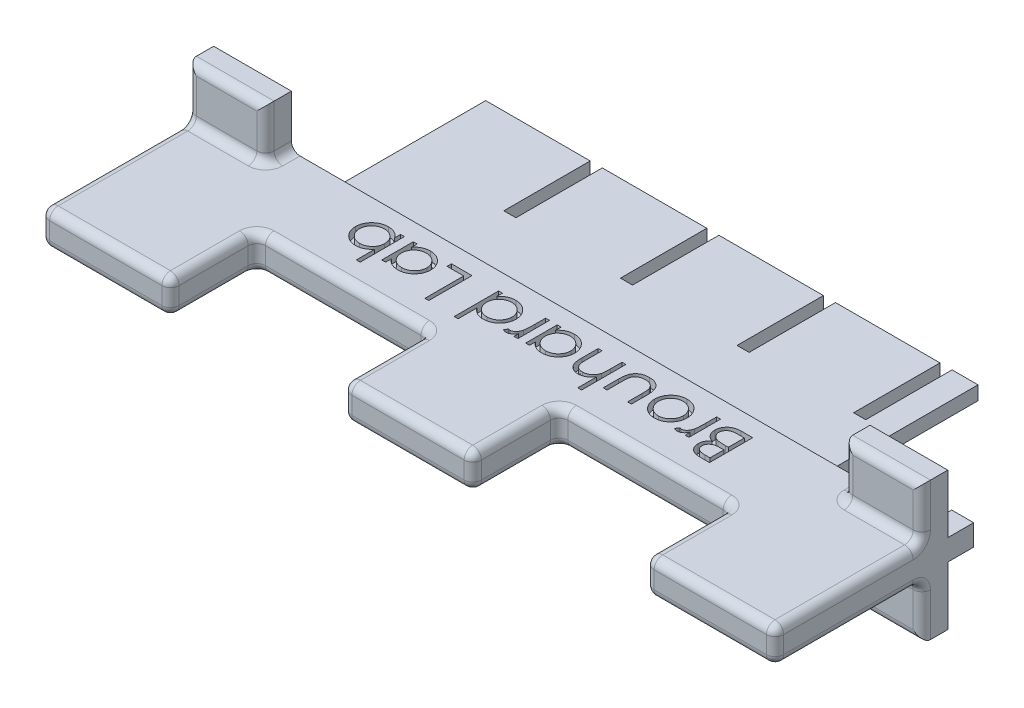
from build123d import *

# Parameters (mm, degrees)
SKETCH1_W           = 85
SKETCH1_H           = 4
BOSS_EXTRUDE1_DEPTH = 10
SKETCH2_W           = 15
SKETCH2_H           = 4
BOSS_EXTRUDE2_DEPTH = 10
SKETCH3_W           = 2.55
SKETCH3_H           = 2.45
BOSS_EXTRUDE3_DEPTH = 3
SKETCH4_W           = 57
SKETCH4_H           = 1.6
BOSS_EXTRUDE4_DEPTH = 7.5
SKETCH6_W           = 9
SKETCH6_H           = 6
BOSS_EXTRUDE6_DEPTH = 3
FILLET1_R           = 1
CUT_EXTRUDE1_DEPTH  = 1
SKETCH5_W           = 12.1
SKETCH5_H           = 1.6
SKETCH5_W_2         = 3
BOSS_EXTRUDE5_DEPTH = 10


with BuildPart() as part:
    # Sketch1 → Boss-Extrude1 (new body)
    with BuildSketch(Plane.XY):
        Rectangle(SKETCH1_W, SKETCH1_H)
    extrude(amount=BOSS_EXTRUDE1_DEPTH)

    # Sketch2 → Boss-Extrude2 (add)
    with BuildSketch(Plane.XY.offset(10)):
        with Locations((-35, 0)):
            Rectangle(SKETCH2_W, SKETCH2_H)
        with Locations((35, 0)):
            Rectangle(SKETCH2_W, SKETCH2_H)
        Rectangle(SKETCH2_W, SKETCH2_H)
    extrude(amount=BOSS_EXTRUDE2_DEPTH)

    # Sketch3 → Boss-Extrude3 (add)
    with BuildSketch(Plane(origin=(0, 0, 0), x_dir=(-1, 0, 0), z_dir=(0, 0, -1))):
        with Locations((-41.225, 0)):
            Rectangle(SKETCH3_W, SKETCH3_H)
        with Locations((41.225, 0)):
            Rectangle(SKETCH3_W, SKETCH3_H)
    extrude(amount=BOSS_EXTRUDE3_DEPTH)

    # Sketch4 → Boss-Extrude4 (add)
    with BuildSketch(Plane(origin=(0, 0, 0), x_dir=(-1, 0, 0), z_dir=(0, 0, -1))):
        Rectangle(SKETCH4_W, SKETCH4_H)
    extrude(amount=BOSS_EXTRUDE4_DEPTH)

    # Sketch6 → Boss-Extrude6 (add)
    with BuildSketch(Plane(origin=(0, 0, 0), x_dir=(-1, 0, 0), z_dir=(0, 0, -1))):
        with Locations((38, -5)):
            Rectangle(SKETCH6_W, SKETCH6_H)
        with Locations((38, 5)):
            Rectangle(SKETCH6_W, SKETCH6_H)
        with Locations((-38, -5)):
            Rectangle(SKETCH6_W, SKETCH6_H)
        with Locations((-38, 5)):
            Rectangle(SKETCH6_W, SKETCH6_H)
    extrude(amount=-BOSS_EXTRUDE6_DEPTH)

    # Fillet1
    fillet1_edges = [part.edges().sort_by_distance(p)[0] for p in [
        (-42.5, 5, 3),
        (-38, 2, 3),
        (-33.5, 5, 3),
        (-33.5, 2, 1.5),
        (-38, 8, 3),
        (42.5, -5, 3),
        (38, -2, 3),
        (33.5, -5, 3),
        (33.5, -2, 1.5),
        (38, -8, 3),
        (42.5, 5, 3),
        (38, 8, 3),
        (33.5, 5, 3),
        (38, 2, 3),
        (33.5, 2, 1.5),
        (-17.5, -2, 10),
        (-27.5, 0, 10),
        (-27.5, -2, 15),
        (-27.5, 2, 15),
        (-42.5, 0, 20),
        (-35, -2, 20),
        (-27.5, 0, 20),
        (-35, 2, 20),
        (17.5, 2, 10),
        (27.5, 0, 10),
        (27.5, 2, 15),
        (27.5, -2, 15),
        (42.5, 0, 20),
        (35, 2, 20),
        (27.5, 0, 20),
        (35, -2, 20),
        (17.5, -2, 10),
        (-17.5, 2, 10),
        (7.5, 0, 10),
        (7.5, -2, 15),
        (7.5, 2, 15),
        (-7.5, 0, 10),
        (-7.5, 2, 15),
        (-7.5, -2, 15),
        (7.5, 0, 20),
        (0, 2, 20),
        (-7.5, 0, 20),
        (0, -2, 20),
        (42.5, -2, 11.5),
        (-42.5, -2, 11.5),
        (-42.5, 2, 11.5),
        (42.5, 2, 11.5),
        (-42.5, -5, 3),
        (-38, -8, 3),
        (-33.5, -5, 3),
        (-38, -2, 3),
        (-33.5, -2, 1.5),
    ]]
    fillet(fillet1_edges, radius=FILLET1_R)

    # Sketch8 → Cut-Extrude1 (cut)
    with BuildSketch(Plane(origin=(0, 2, 0), x_dir=(1, 0, 0), z_dir=(0, 1, 0))):
        with BuildLine():
            Line((21.955128205, -7.045024133), (20.979567308, -7.045024133))
            add(Edge.make_bspline(
                [(20.979567308, -7.045024133), (20.931811586, -7.044777014), (20.839249111, -7.044298035), (20.704660144, -7.036696988), (20.578554958, -7.026592114), (20.461156398, -7.009641733), (20.351700568, -6.992066423), (20.251298675, -6.966270076), (20.159109728, -6.937777071), (20.048409672, -6.893936716), (19.92280529, -6.825852091), (19.787804083, -6.724876123), (19.670452795, -6.603814091), (19.570669416, -6.465854357), (19.490591132, -6.314083016), (19.43339094, -6.151765477), (19.396643358, -5.981632539), (19.392911608, -5.864990679), (19.391025641, -5.806041761)],
                knots=[0, 0, 0, 0, 0.000143243, 0.000277641, 0.000404323, 0.000522601, 0.000633422, 0.000736665, 0.000833282, 0.000922745, 0.001093491, 0.001260157, 0.001426607, 0.001597303, 0.001769346, 0.001939468, 0.002112331, 0.002288957, 0.002288957, 0.002288957, 0.002288957], degree=3))
            add(Edge.make_bspline(
                [(19.391025641, -5.806041761), (19.392566125, -5.750816773), (19.395593321, -5.642294463), (19.425166581, -5.484100137), (19.4698067, -5.333038737), (19.534225102, -5.190566035), (19.616363978, -5.057933935), (19.716298264, -4.937404803), (19.834792937, -4.831345021), (19.923759393, -4.772321243), (19.968950321, -4.742339838)],
                knots=[0, 0, 0, 0, 0.00016551, 0.000325243, 0.000481139, 0.000637145, 0.000792791, 0.000947835, 0.001105294, 0.001267844, 0.001267844, 0.001267844, 0.001267844], degree=3))
            add(Edge.make_bspline(
                [(19.968950321, -4.742339838), (19.912145679, -4.720542475), (19.803464327, -4.678838718), (19.653711211, -4.604821394), (19.524645211, -4.524933301), (19.41460302, -4.438588883), (19.32239544, -4.34296875), (19.240253224, -4.240591123), (19.170541651, -4.127890536), (19.111062126, -4.007309158), (19.063944891, -3.879485542), (19.031238978, -3.745375962), (19.010496783, -3.606499394), (19.007784363, -3.512111636), (19.006410256, -3.464294967)],
                knots=[0, 0, 0, 0, 0.000182459, 0.00034909, 0.000500276, 0.000637148, 0.000767471, 0.00089793, 0.001030217, 0.001164151, 0.001300726, 0.001437979, 0.001577644, 0.001721044, 0.001721044, 0.001721044, 0.001721044], degree=3))
            add(Edge.make_bspline(
                [(19.006410256, -3.464294967), (19.007805885, -3.41548523), (19.010551822, -3.319450707), (19.030807012, -3.178370784), (19.065112767, -3.043553694), (19.112331393, -2.914102037), (19.173883248, -2.790773975), (19.248244287, -2.672600284), (19.337493216, -2.561332318), (19.437996289, -2.45535544), (19.550128803, -2.358444164), (19.673690061, -2.2751618), (19.805513315, -2.203227398), (19.947403728, -2.145396174), (20.098354491, -2.100124903), (20.258400966, -2.068824422), (20.427452272, -2.047649449), (20.543467886, -2.045914087), (20.602964744, -2.045024133)],
                knots=[0, 0, 0, 0, 0.000146402, 0.00028805, 0.000426518, 0.000563092, 0.000700608, 0.000839267, 0.000981145, 0.001127794, 0.001276955, 0.001424748, 0.00157399, 0.001726698, 0.001883553, 0.002046002, 0.002215459, 0.002393845, 0.002393845, 0.002393845, 0.002393845], degree=3))
            Line((20.602964744, -2.045024133), (21.955128205, -2.045024133))
            Line((21.955128205, -2.045024133), (21.955128205, -7.045024133))
        make_face()
        with BuildLine():
            Line((21.506410256, -6.53220362), (21.506410256, -4.929639518))
            Line((21.506410256, -4.929639518), (21.204927885, -4.929639518))
            add(Edge.make_bspline(
                [(21.204927885, -4.929639518), (21.16085778, -4.930206082), (21.075705357, -4.9313008), (20.952063514, -4.934535484), (20.837581625, -4.943196106), (20.731865233, -4.952356158), (20.635622811, -4.966460704), (20.548532434, -4.983720889), (20.469810894, -5.00181496), (20.379071632, -5.032675643), (20.276157749, -5.077807077), (20.16721677, -5.149562501), (20.069164992, -5.232639769), (19.988277934, -5.331182392), (19.920936523, -5.437599512), (19.875598165, -5.552684686), (19.843986577, -5.672472047), (19.841172407, -5.755083607), (19.83974359, -5.797027338)],
                knots=[0, 0, 0, 0, 0.000132227, 0.000255489, 0.000370952, 0.000476596, 0.000573767, 0.000662554, 0.000742964, 0.000815812, 0.000949851, 0.001078759, 0.001205868, 0.001333854, 0.001459773, 0.001581973, 0.001703679, 0.001829203, 0.001829203, 0.001829203, 0.001829203], degree=3))
            add(Edge.make_bspline(
                [(19.83974359, -5.797027338), (19.840440447, -5.824795004), (19.841807408, -5.879264312), (19.85469429, -5.958622966), (19.872478035, -6.034141042), (19.901807859, -6.103782707), (19.936556119, -6.169993364), (19.98109509, -6.230681546), (20.03245262, -6.287491301), (20.092329064, -6.338899898), (20.160479658, -6.385396007), (20.239063252, -6.424101797), (20.325943351, -6.458499162), (20.422931675, -6.48457317), (20.528096305, -6.507209559), (20.643041681, -6.521483941), (20.767075062, -6.530654029), (20.853013063, -6.531675569), (20.897435897, -6.53220362)],
                knots=[0, 0, 0, 0, 8.3229e-05, 0.000163264, 0.000240757, 0.000315341, 0.000389283, 0.000464617, 0.000540481, 0.000618594, 0.000700823, 0.000787274, 0.000880832, 0.000980716, 0.001088168, 0.001203335, 0.00132786, 0.001461107, 0.001461107, 0.001461107, 0.001461107], degree=3))
            Line((20.897435897, -6.53220362), (21.506410256, -6.53220362))
        make_face(mode=Mode.SUBTRACT)
        with BuildLine():
            Line((21.506410256, -4.416819005), (21.506410256, -2.557844646))
            Line((21.506410256, -2.557844646), (20.867387821, -2.557844646))
            add(Edge.make_bspline(
                [(20.867387821, -2.557844646), (20.82165107, -2.558445571), (20.733499514, -2.559603775), (20.606126985, -2.562352033), (20.48869926, -2.57254806), (20.380238634, -2.582323383), (20.281246941, -2.598293401), (20.190761319, -2.61375789), (20.110848501, -2.63651465), (20.017345889, -2.667828353), (19.912764158, -2.717871803), (19.798555972, -2.791464981), (19.697962318, -2.881106895), (19.612615651, -2.984324471), (19.541653639, -3.095395221), (19.492561941, -3.214537751), (19.460753316, -3.337772506), (19.457007017, -3.422035912), (19.455128205, -3.464294967)],
                knots=[0, 0, 0, 0, 0.000137234, 0.000264501, 0.000382034, 0.000490767, 0.000591058, 0.000682796, 0.000765899, 0.000840017, 0.000978463, 0.001112367, 0.001246451, 0.001380849, 0.001513136, 0.001640186, 0.001766022, 0.001892621, 0.001892621, 0.001892621, 0.001892621], degree=3))
            add(Edge.make_bspline(
                [(19.455128205, -3.464294967), (19.455511728, -3.490717987), (19.456272588, -3.543137822), (19.468232548, -3.620102651), (19.484829912, -3.695025725), (19.509289766, -3.766889341), (19.538879538, -3.836930979), (19.577915987, -3.902871611), (19.621948812, -3.967518228), (19.690148998, -4.050208407), (19.790699472, -4.144331407), (19.933635519, -4.235332182), (20.095250073, -4.309910154), (20.212743455, -4.341437989), (20.2734375, -4.357724454)],
                knots=[0, 0, 0, 0, 7.9184e-05, 0.00015709, 0.000233139, 0.000309156, 0.000384516, 0.000460796, 0.000538586, 0.000618995, 0.000781989, 0.000949233, 0.001125381, 0.001313608, 0.001313608, 0.001313608, 0.001313608], degree=3))
            add(Edge.make_bspline(
                [(20.2734375, -4.357724454), (20.297764757, -4.36266062), (20.350511268, -4.373363246), (20.436522534, -4.384653585), (20.535045896, -4.394781387), (20.645660247, -4.402076233), (20.768805516, -4.409907124), (20.904442139, -4.412844185), (21.052666008, -4.416429024), (21.15551238, -4.416685686), (21.208934295, -4.416819005)],
                knots=[0, 0, 0, 0, 7.4449e-05, 0.000161422, 0.000260089, 0.000371555, 0.000493951, 0.000630228, 0.000778496, 0.000938755, 0.000938755, 0.000938755, 0.000938755], degree=3))
            Line((21.208934295, -4.416819005), (21.506410256, -4.416819005))
        make_face(mode=Mode.SUBTRACT)
        with BuildLine():
            Line((18.237179487, -5.698870287), (17.788461538, -5.698870287))
            Line((17.788461538, -5.698870287), (17.788461538, -5.16100971))
            add(Edge.make_bspline(
                [(17.788461538, -5.16100971), (17.755359908, -5.211117117), (17.692053298, -5.306947144), (17.586273377, -5.43343718), (17.479111393, -5.53983342), (17.366921794, -5.622588498), (17.252557594, -5.685650706), (17.136357118, -5.730343447), (17.017481778, -5.757585182), (16.937237879, -5.761174556), (16.897035256, -5.762972851)],
                knots=[0, 0, 0, 0, 0.000180032, 0.00034431, 0.000493764, 0.000631989, 0.000761087, 0.000884414, 0.00100446, 0.00112499, 0.00112499, 0.00112499, 0.00112499], degree=3))
            add(Edge.make_bspline(
                [(16.897035256, -5.762972851), (16.865844687, -5.761310147), (16.801992924, -5.757906343), (16.705041331, -5.732794344), (16.604739598, -5.694222955), (16.540012887, -5.657063647), (16.506410256, -5.637772531)],
                knots=[0, 0, 0, 0, 9.3493e-05, 0.000191394, 0.000298902, 0.000414971, 0.000414971, 0.000414971, 0.000414971], degree=3))
            Line((16.506410256, -5.637772531), (16.752804487, -5.249150736))
            add(Edge.make_bspline(
                [(16.752804487, -5.249150736), (16.774388803, -5.258779687), (16.815359967, -5.277057281), (16.875295061, -5.298688724), (16.930554114, -5.311425747), (16.965759197, -5.313355343), (16.982171474, -5.314254902)],
                knots=[0, 0, 0, 0, 7.0888e-05, 0.000134558, 0.000190943, 0.000240184, 0.000240184, 0.000240184, 0.000240184], degree=3))
            add(Edge.make_bspline(
                [(16.982171474, -5.314254902), (17.018552318, -5.311962095), (17.092095887, -5.307327204), (17.199553418, -5.267726819), (17.305221395, -5.20820996), (17.387285817, -5.138004944), (17.451536641, -5.071852679), (17.497773588, -5.013639038), (17.539299542, -4.947803919), (17.579572406, -4.876841023), (17.616991286, -4.798984205), (17.65042989, -4.714102186), (17.681701622, -4.622897124), (17.699312387, -4.559480067), (17.708333333, -4.526995287)],
                knots=[0, 0, 0, 0, 0.000108839, 0.000220017, 0.000339778, 0.000471355, 0.000542193, 0.000616339, 0.000693851, 0.000775474, 0.000861039, 0.000952734, 0.001049023, 0.001150145, 0.001150145, 0.001150145, 0.001150145], degree=3))
            add(Edge.make_bspline(
                [(17.708333333, -4.526995287), (17.715105579, -4.4980295), (17.73018081, -4.433550753), (17.744447085, -4.325868753), (17.75911049, -4.198727857), (17.769124119, -4.051980366), (17.778583328, -3.885062178), (17.783808984, -3.698693379), (17.788295276, -3.492361731), (17.78840435, -3.348446216), (17.788461538, -3.272988877)],
                knots=[0, 0, 0, 0, 8.9193e-05, 0.000198547, 0.000325526, 0.000473173, 0.000639683, 0.000827079, 0.001032447, 0.001258811, 0.001258811, 0.001258811, 0.001258811], degree=3))
            Line((17.788461538, -3.272988877), (17.788461538, -2.045024133))
            Line((17.788461538, -2.045024133), (18.237179487, -2.045024133))
            Line((18.237179487, -2.045024133), (18.237179487, -5.698870287))
        make_face()
        with BuildLine():
            add(Edge.make_bspline(
                [(14.29286859, -5.762972851), (14.224307927, -5.761517291), (14.089877222, -5.758663293), (13.893032913, -5.728009819), (13.705327588, -5.681525783), (13.525956048, -5.616093456), (13.356402056, -5.530243686), (13.195151776, -5.426425769), (13.042528278, -5.303937317), (12.951070622, -5.209132095), (12.904647436, -5.16100971)],
                knots=[0, 0, 0, 0, 0.000205526, 0.000402987, 0.000596112, 0.000784972, 0.000974447, 0.001165038, 0.001359476, 0.001559909, 0.001559909, 0.001559909, 0.001559909], degree=3))
            add(Edge.make_bspline(
                [(12.904647436, -5.16100971), (12.864673216, -5.11498973), (12.785498387, -5.023840384), (12.683975931, -4.876046652), (12.59651656, -4.722989365), (12.526426616, -4.562636041), (12.471162296, -4.396386511), (12.431925587, -4.223669352), (12.408587109, -4.044865999), (12.405440013, -3.923431945), (12.403846154, -3.861931185)],
                knots=[0, 0, 0, 0, 0.000182745, 0.000361954, 0.000536876, 0.000710881, 0.000886036, 0.001061708, 0.001241475, 0.001425944, 0.001425944, 0.001425944, 0.001425944], degree=3))
            add(Edge.make_bspline(
                [(12.403846154, -3.861931185), (12.405248064, -3.800073959), (12.408018305, -3.677841197), (12.434223472, -3.497813533), (12.474982163, -3.323249495), (12.533313369, -3.154879952), (12.608110636, -2.992190127), (12.699383171, -2.835891045), (12.807770716, -2.685672654), (12.930635425, -2.542816985), (13.066416897, -2.411135675), (13.21375075, -2.296436369), (13.369848434, -2.197755629), (13.536840837, -2.119375683), (13.712350874, -2.056195988), (13.8974949, -2.012629522), (14.09210775, -1.986052796), (14.225006973, -1.982656037), (14.29286859, -1.980921569)],
                knots=[0, 0, 0, 0, 0.00018547, 0.000366497, 0.000544574, 0.000722589, 0.000900065, 0.001080956, 0.001264689, 0.001455025, 0.001645575, 0.001831106, 0.002014249, 0.002198383, 0.002383395, 0.002572886, 0.002767942, 0.002971467, 0.002971467, 0.002971467, 0.002971467], degree=3))
            add(Edge.make_bspline(
                [(14.29286859, -1.980921569), (14.361059424, -1.982670388), (14.494614618, -1.986095539), (14.689960267, -2.012431829), (14.875883807, -2.056661478), (15.052224048, -2.118593533), (15.219215773, -2.198399418), (15.37588985, -2.296052412), (15.523293198, -2.411193757), (15.65911724, -2.542801247), (15.781970535, -2.685676709), (15.890361026, -2.835889993), (15.981632796, -2.992190401), (16.056430263, -3.154879879), (16.114761415, -3.323249515), (16.155520121, -3.497813528), (16.181725284, -3.677841198), (16.184495525, -3.80007396), (16.185897436, -3.861931185)],
                knots=[0, 0, 0, 0, 0.000204526, 0.000400574, 0.000590065, 0.000776965, 0.000960195, 0.001144188, 0.00132972, 0.001520269, 0.001710605, 0.001894339, 0.00207523, 0.002252706, 0.002430721, 0.002608798, 0.002789825, 0.002975294, 0.002975294, 0.002975294, 0.002975294], degree=3))
            add(Edge.make_bspline(
                [(16.185897436, -3.861931185), (16.184296519, -3.923099043), (16.18112698, -4.044200892), (16.157756652, -4.22264832), (16.118946868, -4.394836864), (16.062916427, -4.560178538), (15.992956591, -4.720146456), (15.90637746, -4.873764934), (15.803872945, -5.02091287), (15.725005709, -5.111941341), (15.685096154, -5.158004902)],
                knots=[0, 0, 0, 0, 0.000183468, 0.000363236, 0.000538908, 0.000712162, 0.000886167, 0.001061962, 0.001240348, 0.001423094, 0.001423094, 0.001423094, 0.001423094], degree=3))
            add(Edge.make_bspline(
                [(15.685096154, -5.158004902), (15.638739114, -5.20653651), (15.547569839, -5.301982456), (15.394241809, -5.424229232), (15.233685171, -5.529446865), (15.063037498, -5.615253429), (14.883167202, -5.681407061), (14.694066814, -5.728226774), (14.496506031, -5.758527704), (14.361424213, -5.761476369), (14.29286859, -5.762972851)],
                knots=[0, 0, 0, 0, 0.00020114, 0.000395577, 0.000586713, 0.000776188, 0.000967274, 0.001160399, 0.001359841, 0.001565367, 0.001565367, 0.001565367, 0.001565367], degree=3))
        make_face()
        with BuildLine():
            add(Edge.make_bspline(
                [(14.294871795, -5.314254902), (14.343354042, -5.31287684), (14.439066976, -5.310156289), (14.579952881, -5.289466071), (14.715578773, -5.256679949), (14.84621924, -5.210117374), (14.971369132, -5.149920796), (15.091165691, -5.076401027), (15.205288814, -4.989167289), (15.312855022, -4.88995037), (15.412753003, -4.782192755), (15.499001382, -4.666286529), (15.572889716, -4.545452386), (15.633262525, -4.419007361), (15.679580189, -4.286604065), (15.712397714, -4.149000046), (15.733127199, -4.005785755), (15.735814091, -3.908409845), (15.737179487, -3.858926377)],
                knots=[0, 0, 0, 0, 0.000145402, 0.00028705, 0.000426247, 0.000563423, 0.000702299, 0.000842129, 0.000984361, 0.00113252, 0.001280679, 0.00142451, 0.001565195, 0.001704975, 0.001844039, 0.001985183, 0.002128814, 0.002277217, 0.002277217, 0.002277217, 0.002277217], degree=3))
            add(Edge.make_bspline(
                [(15.737179487, -3.858926377), (15.734890082, -3.794992084), (15.730346041, -3.668094469), (15.693206633, -3.48126298), (15.631516344, -3.301562306), (15.546449569, -3.131156088), (15.441687276, -2.973216762), (15.31918926, -2.831196974), (15.177261944, -2.710573578), (15.020738225, -2.609127271), (14.851836243, -2.5292384), (14.673387712, -2.471947456), (14.487017459, -2.435206285), (14.359480893, -2.431511347), (14.294871795, -2.429639518)],
                knots=[0, 0, 0, 0, 0.000191683, 0.000380455, 0.000568919, 0.000760186, 0.000950198, 0.001136194, 0.00132088, 0.001507019, 0.001694298, 0.001879594, 0.002068178, 0.002261801, 0.002261801, 0.002261801, 0.002261801], degree=3))
            add(Edge.make_bspline(
                [(14.294871795, -2.429639518), (14.23025898, -2.431500504), (14.102715078, -2.435174039), (13.916085515, -2.472133599), (13.737147914, -2.528989279), (13.568070317, -2.609217501), (13.411475317, -2.710190138), (13.270561459, -2.831884154), (13.147008507, -2.972843418), (13.04214248, -3.130946672), (12.958446366, -3.301827223), (12.896465966, -3.481229869), (12.859415628, -3.668102902), (12.854859565, -3.794994909), (12.852564103, -3.858926377)],
                knots=[0, 0, 0, 0, 0.000193623, 0.000382206, 0.000568456, 0.000755734, 0.000941873, 0.001125801, 0.001312456, 0.001502468, 0.001693291, 0.001881755, 0.002070527, 0.00226221, 0.00226221, 0.00226221, 0.00226221], degree=3))
            add(Edge.make_bspline(
                [(12.852564103, -3.858926377), (12.85391927, -3.908413822), (12.856586033, -4.00579756), (12.877461924, -4.148954918), (12.909764333, -4.286878115), (12.958078967, -4.418473367), (13.016348399, -4.546067931), (13.092028067, -4.665924648), (13.177874936, -4.782266279), (13.277956043, -4.889885455), (13.385510177, -4.98952979), (13.500490643, -5.076083255), (13.620342842, -5.149962779), (13.745532283, -5.210124787), (13.875877117, -5.256500729), (14.011091241, -5.289608892), (14.151353237, -5.310080851), (14.246726302, -5.312854653), (14.294871795, -5.314254902)],
                knots=[0, 0, 0, 0, 0.000148403, 0.000292034, 0.000433178, 0.000572578, 0.00071193, 0.000853138, 0.000996969, 0.001145128, 0.001293287, 0.001436317, 0.001576147, 0.001715023, 0.001852199, 0.001990424, 0.002132072, 0.002276473, 0.002276473, 0.002276473, 0.002276473], degree=3))
        make_face(mode=Mode.SUBTRACT)
        with BuildLine():
            Line((11.570512821, -5.698870287), (11.121794872, -5.698870287))
            Line((11.121794872, -5.698870287), (11.121794872, -4.004158749))
            add(Edge.make_bspline(
                [(11.121794872, -4.004158749), (11.121592151, -3.954411964), (11.121204354, -3.859248695), (11.118574439, -3.722312714), (11.112388591, -3.597431696), (11.104654555, -3.484533501), (11.094708647, -3.383637227), (11.082875275, -3.295095289), (11.069648958, -3.217903597), (11.056702224, -3.171413089), (11.05068109, -3.149791761)],
                knots=[0, 0, 0, 0, 0.000149242, 0.000285493, 0.000410838, 0.000524302, 0.000624962, 0.000714911, 0.000792314, 0.000859608, 0.000859608, 0.000859608, 0.000859608], degree=3))
            add(Edge.make_bspline(
                [(11.05068109, -3.149791761), (11.041021805, -3.122616307), (11.02190405, -3.06883037), (10.987228565, -2.991130691), (10.944327515, -2.919170094), (10.897397624, -2.850149082), (10.843207537, -2.786203671), (10.78254961, -2.72691621), (10.716500508, -2.671595092), (10.619751651, -2.6048734), (10.487494763, -2.534263345), (10.314242396, -2.472488378), (10.126045943, -2.436112097), (9.995820794, -2.431836921), (9.928886218, -2.429639518)],
                knots=[0, 0, 0, 0, 8.6516e-05, 0.000171232, 0.000254721, 0.000337515, 0.000421387, 0.00050567, 0.000591721, 0.00067952, 0.000857864, 0.001039709, 0.001229465, 0.001430146, 0.001430146, 0.001430146, 0.001430146], degree=3))
            add(Edge.make_bspline(
                [(9.928886218, -2.429639518), (9.86194316, -2.431828713), (9.732748927, -2.436053669), (9.546518851, -2.471939165), (9.375968682, -2.530483395), (9.223089747, -2.613350563), (9.088841758, -2.714376404), (8.976981124, -2.832969142), (8.884684323, -2.965323174), (8.844385248, -3.064072442), (8.82411859, -3.113734069)],
                knots=[0, 0, 0, 0, 0.000200681, 0.000387296, 0.000566586, 0.000739571, 0.000906841, 0.001068376, 0.001227003, 0.001387484, 0.001387484, 0.001387484, 0.001387484], degree=3))
            add(Edge.make_bspline(
                [(8.82411859, -3.113734069), (8.8181224, -3.1336855), (8.80486629, -3.177793242), (8.790725551, -3.252630176), (8.777460105, -3.341789135), (8.768616165, -3.446206446), (8.758522511, -3.564961319), (8.755037146, -3.698667884), (8.750059864, -3.846538026), (8.750020544, -3.950065981), (8.75, -4.004158749)],
                knots=[0, 0, 0, 0, 6.2462e-05, 0.000138088, 0.000228176, 0.000332823, 0.000452355, 0.000585662, 0.000733953, 0.000896216, 0.000896216, 0.000896216, 0.000896216], degree=3))
            Line((8.75, -4.004158749), (8.75, -5.698870287))
            Line((8.75, -5.698870287), (8.301282051, -5.698870287))
            Line((8.301282051, -5.698870287), (8.301282051, -3.920024133))
            add(Edge.make_bspline(
                [(8.301282051, -3.920024133), (8.30191531, -3.859585653), (8.303143917, -3.742326733), (8.310980731, -3.571916291), (8.324614367, -3.412799073), (8.344773775, -3.265462167), (8.369229918, -3.129870336), (8.400154934, -3.00598092), (8.437277048, -2.893621613), (8.479165629, -2.791153018), (8.528529202, -2.698158121), (8.581390514, -2.610389295), (8.640827886, -2.528135886), (8.705652894, -2.450645369), (8.777741804, -2.379798189), (8.85333008, -2.311961845), (8.93610888, -2.251321381), (9.023288539, -2.194646502), (9.117066908, -2.144351467), (9.216637391, -2.100832577), (9.321894658, -2.063022013), (9.433003103, -2.033803946), (9.549897573, -2.009153726), (9.67242881, -1.992746928), (9.800829998, -1.982271357), (9.888132562, -1.981379054), (9.932892628, -1.980921569)],
                knots=[0, 0, 0, 0, 0.000181315, 0.000351776, 0.000511647, 0.000660239, 0.000797754, 0.000924804, 0.001042946, 0.001152506, 0.001256441, 0.001358477, 0.001459659, 0.001560587, 0.001661157, 0.001762636, 0.001865001, 0.001968632, 0.00207439, 0.002183817, 0.002294379, 0.002409546, 0.002528193, 0.002652561, 0.002780158, 0.002914407, 0.002914407, 0.002914407, 0.002914407], degree=3))
            add(Edge.make_bspline(
                [(9.932892628, -1.980921569), (9.977316456, -1.981406186), (10.064613414, -1.982358504), (10.192711845, -1.992570693), (10.315507575, -2.00940504), (10.432494069, -2.033606354), (10.544142851, -2.063257518), (10.649911875, -2.100566743), (10.749934706, -2.144600485), (10.84442655, -2.194693497), (10.933073912, -2.251115088), (11.015677547, -2.313213364), (11.093710062, -2.379368112), (11.165005381, -2.451835522), (11.23008642, -2.530073038), (11.28923533, -2.613729086), (11.343463789, -2.701858176), (11.392537938, -2.79623559), (11.434697953, -2.899909467), (11.471919623, -3.014619732), (11.502363426, -3.141623289), (11.527138371, -3.28081177), (11.547069003, -3.431518969), (11.560906348, -3.594616706), (11.568643249, -3.769707694), (11.569876194, -3.890636109), (11.570512821, -3.953077018)],
                knots=[0, 0, 0, 0, 0.000133247, 0.000261843, 0.000385219, 0.000504847, 0.000620013, 0.00073152, 0.000840947, 0.000947589, 0.001052063, 0.001155829, 0.001257407, 0.001358687, 0.001460383, 0.00156238, 0.001665793, 0.001770617, 0.001881102, 0.002001148, 0.002132087, 0.002272558, 0.00242512, 0.002587985, 0.002763448, 0.002950772, 0.002950772, 0.002950772, 0.002950772], degree=3))
            Line((11.570512821, -3.953077018), (11.570512821, -5.698870287))
        make_face()
        with BuildLine():
            Line((7.275641026, -7.173229261), (6.826923077, -7.173229261))
            Line((6.826923077, -7.173229261), (6.826923077, -5.00876612))
            add(Edge.make_bspline(
                [(6.826923077, -5.00876612), (6.778678808, -5.068888094), (6.684893793, -5.185762911), (6.528113976, -5.339904506), (6.36474826, -5.471196487), (6.193410264, -5.578408978), (6.014828183, -5.661579829), (5.828563194, -5.719766634), (5.635090167, -5.756050633), (5.503296595, -5.760649137), (5.436698718, -5.762972851)],
                knots=[0, 0, 0, 0, 0.000231093, 0.000449235, 0.000658061, 0.000858722, 0.001054107, 0.001247341, 0.001442817, 0.001642498, 0.001642498, 0.001642498, 0.001642498], degree=3))
            add(Edge.make_bspline(
                [(5.436698718, -5.762972851), (5.369051259, -5.760620551), (5.236582495, -5.756014225), (5.044402774, -5.715426657), (4.863656734, -5.651196128), (4.696758785, -5.560924861), (4.546286047, -5.448841659), (4.415775284, -5.31738737), (4.306291209, -5.168293369), (4.233038251, -5.029320354), (4.185028125, -4.905733149), (4.154679673, -4.799671692), (4.128934509, -4.68150037), (4.106507375, -4.551264166), (4.091559078, -4.408342759), (4.079552578, -4.253379458), (4.071014758, -4.086383599), (4.070683898, -3.970783239), (4.070512821, -3.91100971)],
                knots=[0, 0, 0, 0, 0.000202742, 0.000397014, 0.000586474, 0.000776485, 0.000963986, 0.001147421, 0.001330122, 0.001516953, 0.001616837, 0.001727454, 0.0018475, 0.00197956, 0.002123683, 0.002278397, 0.002445857, 0.002625155, 0.002625155, 0.002625155, 0.002625155], degree=3))
            Line((4.070512821, -3.91100971), (4.070512821, -2.045024133))
            Line((4.070512821, -2.045024133), (4.519230769, -2.045024133))
            Line((4.519230769, -2.045024133), (4.519230769, -3.763774133))
            add(Edge.make_bspline(
                [(4.519230769, -3.763774133), (4.519501544, -3.813520868), (4.52001949, -3.908677905), (4.521752659, -4.044914373), (4.525533642, -4.16814974), (4.531869413, -4.278639822), (4.53824468, -4.376234881), (4.547283145, -4.46109433), (4.557720701, -4.532685817), (4.567105279, -4.575778103), (4.571314103, -4.595104261)],
                knots=[0, 0, 0, 0, 0.000149242, 0.000285475, 0.000408737, 0.000519077, 0.000617484, 0.0007021, 0.000775053, 0.000834376, 0.000834376, 0.000834376, 0.000834376], degree=3))
            add(Edge.make_bspline(
                [(4.571314103, -4.595104261), (4.587558684, -4.651851981), (4.618706291, -4.760660919), (4.692549434, -4.908198617), (4.782632802, -5.035130852), (4.894290172, -5.137852366), (5.023812243, -5.21879062), (5.172428658, -5.273933897), (5.338240367, -5.309099366), (5.454866892, -5.312485195), (5.515825321, -5.314254902)],
                knots=[0, 0, 0, 0, 0.000176748, 0.000338899, 0.000492364, 0.000641202, 0.000791008, 0.00094763, 0.001114405, 0.001297029, 0.001297029, 0.001297029, 0.001297029], degree=3))
            add(Edge.make_bspline(
                [(5.515825321, -5.314254902), (5.551925349, -5.313584935), (5.623366372, -5.312259087), (5.729246241, -5.298610846), (5.8322736, -5.277055291), (5.932171925, -5.245215815), (6.029144995, -5.206505033), (6.123586995, -5.15899916), (6.21420543, -5.101559446), (6.302169918, -5.036911618), (6.384056208, -4.965394032), (6.460236741, -4.889895628), (6.528148933, -4.809503542), (6.589675418, -4.725503187), (6.642787274, -4.636743532), (6.689148815, -4.544080206), (6.728485525, -4.44739143), (6.748032228, -4.380284199), (6.7578125, -4.346706826)],
                knots=[0, 0, 0, 0, 0.000108247, 0.000214218, 0.000319711, 0.000423617, 0.000528331, 0.0006327, 0.00074025, 0.000849828, 0.000959881, 0.001066117, 0.001171281, 0.001275259, 0.001378152, 0.001481176, 0.00158589, 0.001690753, 0.001690753, 0.001690753, 0.001690753], degree=3))
            add(Edge.make_bspline(
                [(6.7578125, -4.346706826), (6.763440253, -4.322391181), (6.77570382, -4.2694044), (6.789010725, -4.182012509), (6.800921863, -4.080460549), (6.81099122, -3.964902548), (6.817167057, -3.834915059), (6.823821687, -3.691385118), (6.82629885, -3.533413659), (6.826708783, -3.423562934), (6.826923077, -3.366137915)],
                knots=[0, 0, 0, 0, 7.4853e-05, 0.000163113, 0.000264986, 0.000381603, 0.000511, 0.000655356, 0.000812636, 0.000984915, 0.000984915, 0.000984915, 0.000984915], degree=3))
            Line((6.826923077, -3.366137915), (6.826923077, -2.045024133))
            Line((6.826923077, -2.045024133), (7.275641026, -2.045024133))
            Line((7.275641026, -2.045024133), (7.275641026, -7.173229261))
        make_face()
        with BuildLine():
            Line((-0.673076923, -5.698870287), (-0.673076923, -2.045024133))
            Line((-0.673076923, -2.045024133), (-0.224358974, -2.045024133))
            Line((-0.224358974, -2.045024133), (-0.224358974, -2.677035351))
            add(Edge.make_bspline(
                [(-0.224358974, -2.677035351), (-0.173692153, -2.619914798), (-0.074668173, -2.508277549), (0.089136249, -2.361533046), (0.264203306, -2.241723382), (0.447550404, -2.144473643), (0.640596711, -2.07116495), (0.842208477, -2.019519884), (1.052227954, -1.985924035), (1.195449856, -1.982604018), (1.268028846, -1.980921569)],
                knots=[0, 0, 0, 0, 0.000228947, 0.000447457, 0.00065777, 0.000863866, 0.001068669, 0.001275649, 0.001487424, 0.001705002, 0.001705002, 0.001705002, 0.001705002], degree=3))
            add(Edge.make_bspline(
                [(1.268028846, -1.980921569), (1.33255467, -1.982673239), (1.459802451, -1.986127609), (1.646984326, -2.01293508), (1.827125421, -2.055963389), (2.000340544, -2.115878617), (2.16545602, -2.194944018), (2.323402232, -2.290624075), (2.474547798, -2.403447762), (2.616018245, -2.532931528), (2.746457503, -2.673420564), (2.860578679, -2.823701191), (2.957300092, -2.98170931), (3.03678777, -3.14740051), (3.098299504, -3.320653672), (3.141095026, -3.50134994), (3.16787361, -3.689188645), (3.17132623, -3.817102795), (3.173076923, -3.881963236)],
                knots=[0, 0, 0, 0, 0.000193519, 0.000381629, 0.000566016, 0.000748473, 0.000930368, 0.001114167, 0.001301667, 0.001495236, 0.001688742, 0.001876044, 0.002060364, 0.002243594, 0.002426383, 0.002610771, 0.002799872, 0.002994392, 0.002994392, 0.002994392, 0.002994392], degree=3))
            add(Edge.make_bspline(
                [(3.173076923, -3.881963236), (3.1712874, -3.945483083), (3.167749609, -4.071058395), (3.141381566, -4.255738336), (3.097074815, -4.43363601), (3.034777431, -4.604092418), (2.955247483, -4.767794043), (2.856862681, -4.923460082), (2.742782629, -5.073471787), (2.610949305, -5.213018547), (2.468209109, -5.341451795), (2.316217898, -5.454549666), (2.156870853, -5.549984408), (1.989848458, -5.627563574), (1.81633338, -5.689212702), (1.635007518, -5.732188081), (1.446695469, -5.757450724), (1.318853253, -5.761114455), (1.25400641, -5.762972851)],
                knots=[0, 0, 0, 0, 0.000190518, 0.000376644, 0.000558351, 0.000739594, 0.000920119, 0.001103261, 0.001291171, 0.001484625, 0.001678266, 0.00186657, 0.002052086, 0.00223446, 0.002418194, 0.002603555, 0.002792521, 0.002987041, 0.002987041, 0.002987041, 0.002987041], degree=3))
            add(Edge.make_bspline(
                [(1.25400641, -5.762972851), (1.179433695, -5.760926632), (1.03320012, -5.756914093), (0.81900525, -5.723236763), (0.616281151, -5.666868078), (0.423271915, -5.589930632), (0.242689948, -5.486323272), (0.072799241, -5.358126181), (-0.084384391, -5.202231444), (-0.176893656, -5.083637559), (-0.224358974, -5.022788556)],
                knots=[0, 0, 0, 0, 0.000223629, 0.000438526, 0.00064848, 0.000853819, 0.001060171, 0.00127111, 0.001490669, 0.00172203, 0.00172203, 0.00172203, 0.00172203], degree=3))
            Line((-0.224358974, -5.022788556), (-0.224358974, -5.698870287))
            Line((-0.224358974, -5.698870287), (-0.673076923, -5.698870287))
        make_face()
        with BuildLine():
            add(Edge.make_bspline(
                [(1.247996795, -5.314254902), (1.313587334, -5.311919162), (1.443052626, -5.307308782), (1.633135329, -5.271375167), (1.81493707, -5.211432861), (1.988162207, -5.129927244), (2.148028307, -5.025521063), (2.293274093, -4.90241808), (2.4199622, -4.759110049), (2.527080559, -4.598889493), (2.61600865, -4.428155027), (2.677375939, -4.248376808), (2.71813637, -4.064413876), (2.722279372, -3.93960414), (2.724358974, -3.876955223)],
                knots=[0, 0, 0, 0, 0.000196682, 0.000388218, 0.000577945, 0.000769701, 0.000960837, 0.001149109, 0.001339255, 0.001532603, 0.001726118, 0.001914908, 0.002101131, 0.002288816, 0.002288816, 0.002288816, 0.002288816], degree=3))
            add(Edge.make_bspline(
                [(2.724358974, -3.876955223), (2.721659394, -3.814696014), (2.716270816, -3.690421632), (2.678628159, -3.506176784), (2.612554386, -3.327571475), (2.52557156, -3.154636161), (2.41676702, -2.993220534), (2.290328958, -2.847266396), (2.144346166, -2.722265786), (1.983072348, -2.617564507), (1.811006067, -2.533340742), (1.629993631, -2.473937453), (1.443190032, -2.436430737), (1.315946515, -2.431910872), (1.252003205, -2.429639518)],
                knots=[0, 0, 0, 0, 0.000186753, 0.000372773, 0.00056129, 0.00075659, 0.000952159, 0.001143808, 0.001334144, 0.001526666, 0.001719289, 0.001907113, 0.002096868, 0.002288551, 0.002288551, 0.002288551, 0.002288551], degree=3))
            add(Edge.make_bspline(
                [(1.252003205, -2.429639518), (1.187080663, -2.432002624), (1.058284568, -2.436690656), (0.867544613, -2.472872088), (0.682784064, -2.533558691), (0.505507589, -2.61619592), (0.340640106, -2.718645983), (0.193357608, -2.839118095), (0.066119696, -2.97708118), (-0.038639755, -3.131710873), (-0.122341141, -3.29936144), (-0.181608072, -3.478428524), (-0.217604718, -3.667848043), (-0.222076425, -3.797668511), (-0.224358974, -3.86393439)],
                knots=[0, 0, 0, 0, 0.000194682, 0.000386219, 0.000580065, 0.000776779, 0.000971601, 0.00116089, 0.001345905, 0.001532593, 0.001719381, 0.001906254, 0.002096806, 0.002295487, 0.002295487, 0.002295487, 0.002295487], degree=3))
            add(Edge.make_bspline(
                [(-0.224358974, -3.86393439), (-0.222988015, -3.914416985), (-0.220289533, -4.013782709), (-0.199674743, -4.159679441), (-0.166880858, -4.29929803), (-0.120676169, -4.432791295), (-0.059958997, -4.559398956), (0.013194296, -4.680113441), (0.100284193, -4.793810311), (0.198660327, -4.90034558), (0.307556085, -4.997030357), (0.42335261, -5.082247508), (0.545758559, -5.154364667), (0.674688011, -5.212077257), (0.809147942, -5.259094257), (0.950427125, -5.290148173), (1.097101723, -5.311539529), (1.197168848, -5.313340248), (1.247996795, -5.314254902)],
                knots=[0, 0, 0, 0, 0.000151404, 0.000298012, 0.000441104, 0.000581114, 0.000720894, 0.000861579, 0.00100381, 0.001149818, 0.001295962, 0.001440002, 0.001580519, 0.001721272, 0.001863175, 0.002007015, 0.002154615, 0.002306977, 0.002306977, 0.002306977, 0.002306977], degree=3))
        make_face(mode=Mode.SUBTRACT)
        with BuildLine():
            Line((-1.570512821, -5.698870287), (-2.019230769, -5.698870287))
            Line((-2.019230769, -5.698870287), (-2.019230769, -5.16100971))
            add(Edge.make_bspline(
                [(-2.019230769, -5.16100971), (-2.052332399, -5.211117117), (-2.11563901, -5.306947144), (-2.221418931, -5.43343718), (-2.328580915, -5.53983342), (-2.440770514, -5.622588498), (-2.555134714, -5.685650706), (-2.67133519, -5.730343447), (-2.79021053, -5.757585182), (-2.870454429, -5.761174556), (-2.910657051, -5.762972851)],
                knots=[0, 0, 0, 0, 0.000180032, 0.00034431, 0.000493764, 0.000631989, 0.000761087, 0.000884414, 0.00100446, 0.00112499, 0.00112499, 0.00112499, 0.00112499], degree=3))
            add(Edge.make_bspline(
                [(-2.910657051, -5.762972851), (-2.94184762, -5.761310147), (-3.005699384, -5.757906343), (-3.102650976, -5.732794344), (-3.202952709, -5.694222955), (-3.267679421, -5.657063647), (-3.301282051, -5.637772531)],
                knots=[0, 0, 0, 0, 9.3493e-05, 0.000191394, 0.000298902, 0.000414971, 0.000414971, 0.000414971, 0.000414971], degree=3))
            Line((-3.301282051, -5.637772531), (-3.054887821, -5.249150736))
            add(Edge.make_bspline(
                [(-3.054887821, -5.249150736), (-3.033303505, -5.258779687), (-2.992332341, -5.277057281), (-2.932397246, -5.298688724), (-2.877138194, -5.311425747), (-2.84193311, -5.313355343), (-2.825520833, -5.314254902)],
                knots=[0, 0, 0, 0, 7.0888e-05, 0.000134558, 0.000190943, 0.000240184, 0.000240184, 0.000240184, 0.000240184], degree=3))
            add(Edge.make_bspline(
                [(-2.825520833, -5.314254902), (-2.78913999, -5.311962095), (-2.715596421, -5.307327204), (-2.608138889, -5.267726819), (-2.502470912, -5.20820996), (-2.420406491, -5.138004944), (-2.356155667, -5.071852679), (-2.309918719, -5.013639038), (-2.268392765, -4.947803919), (-2.228119902, -4.876841023), (-2.190701022, -4.798984205), (-2.157262418, -4.714102186), (-2.125990686, -4.622897124), (-2.10837992, -4.559480067), (-2.099358974, -4.526995287)],
                knots=[0, 0, 0, 0, 0.000108839, 0.000220017, 0.000339778, 0.000471355, 0.000542193, 0.000616339, 0.000693851, 0.000775474, 0.000861039, 0.000952734, 0.001049023, 0.001150145, 0.001150145, 0.001150145, 0.001150145], degree=3))
            add(Edge.make_bspline(
                [(-2.099358974, -4.526995287), (-2.092586729, -4.4980295), (-2.077511498, -4.433550753), (-2.063245223, -4.325868753), (-2.048581818, -4.198727857), (-2.038568188, -4.051980366), (-2.02910898, -3.885062178), (-2.023883323, -3.698693379), (-2.019397031, -3.492361731), (-2.019287958, -3.348446216), (-2.019230769, -3.272988877)],
                knots=[0, 0, 0, 0, 8.9193e-05, 0.000198547, 0.000325526, 0.000473173, 0.000639683, 0.000827079, 0.001032447, 0.001258811, 0.001258811, 0.001258811, 0.001258811], degree=3))
            Line((-2.019230769, -3.272988877), (-2.019230769, -2.045024133))
            Line((-2.019230769, -2.045024133), (-1.570512821, -2.045024133))
            Line((-1.570512821, -2.045024133), (-1.570512821, -5.698870287))
        make_face()
        with BuildLine():
            Line((-7.467948718, -7.173229261), (-7.467948718, -2.045024133))
            Line((-7.467948718, -2.045024133), (-7.019230769, -2.045024133))
            Line((-7.019230769, -2.045024133), (-7.019230769, -2.677035351))
            add(Edge.make_bspline(
                [(-7.019230769, -2.677035351), (-6.968563948, -2.619914798), (-6.869539967, -2.508277549), (-6.705735546, -2.361533046), (-6.530668489, -2.241723382), (-6.347321391, -2.144473643), (-6.154275084, -2.07116495), (-5.952663318, -2.019519884), (-5.74264384, -1.985924035), (-5.599421939, -1.982604018), (-5.526842949, -1.980921569)],
                knots=[0, 0, 0, 0, 0.000228947, 0.000447457, 0.00065777, 0.000863866, 0.001068669, 0.001275649, 0.001487424, 0.001705002, 0.001705002, 0.001705002, 0.001705002], degree=3))
            add(Edge.make_bspline(
                [(-5.526842949, -1.980921569), (-5.462317125, -1.982673239), (-5.335069344, -1.986127609), (-5.147887469, -2.01293508), (-4.967746374, -2.055963389), (-4.794531251, -2.115878617), (-4.629415775, -2.194944018), (-4.471469563, -2.290624075), (-4.320323997, -2.403447762), (-4.17885355, -2.532931528), (-4.048414292, -2.673420564), (-3.934293116, -2.823701191), (-3.837571703, -2.98170931), (-3.758084025, -3.14740051), (-3.696572291, -3.320653672), (-3.653776768, -3.50134994), (-3.626998185, -3.689188645), (-3.623545565, -3.817102795), (-3.621794872, -3.881963236)],
                knots=[0, 0, 0, 0, 0.000193519, 0.000381629, 0.000566016, 0.000748473, 0.000930368, 0.001114167, 0.001301667, 0.001495236, 0.001688742, 0.001876044, 0.002060364, 0.002243594, 0.002426383, 0.002610771, 0.002799872, 0.002994392, 0.002994392, 0.002994392, 0.002994392], degree=3))
            add(Edge.make_bspline(
                [(-3.621794872, -3.881963236), (-3.623584395, -3.945483083), (-3.627122186, -4.071058395), (-3.653490229, -4.255738336), (-3.69779698, -4.43363601), (-3.760094364, -4.604092418), (-3.839624312, -4.767794043), (-3.938009114, -4.923460082), (-4.052089166, -5.073471787), (-4.18392249, -5.213018547), (-4.326662686, -5.341451795), (-4.478653896, -5.454549666), (-4.638000942, -5.549984408), (-4.805023337, -5.627563574), (-4.978538415, -5.689212702), (-5.159864277, -5.732188081), (-5.348176326, -5.757450724), (-5.476018542, -5.761114455), (-5.540865385, -5.762972851)],
                knots=[0, 0, 0, 0, 0.000190518, 0.000376644, 0.000558351, 0.000739594, 0.000920119, 0.001103261, 0.001291171, 0.001484625, 0.001678266, 0.00186657, 0.002052086, 0.00223446, 0.002418194, 0.002603555, 0.002792521, 0.002987041, 0.002987041, 0.002987041, 0.002987041], degree=3))
            add(Edge.make_bspline(
                [(-5.540865385, -5.762972851), (-5.615472135, -5.76077313), (-5.761916895, -5.756455323), (-5.97611826, -5.719140017), (-6.179467672, -5.659410978), (-6.371957323, -5.5745689), (-6.551897612, -5.463999433), (-6.721693963, -5.33102787), (-6.878744722, -5.172311274), (-6.971688123, -5.052847362), (-7.019230769, -4.991738877)],
                knots=[0, 0, 0, 0, 0.000223681, 0.00043906, 0.00065012, 0.000858193, 0.001068105, 0.001282101, 0.001503782, 0.00173592, 0.00173592, 0.00173592, 0.00173592], degree=3))
            Line((-7.019230769, -4.991738877), (-7.019230769, -7.173229261))
            Line((-7.019230769, -7.173229261), (-7.467948718, -7.173229261))
        make_face()
        with BuildLine():
            add(Edge.make_bspline(
                [(-5.546875, -5.314254902), (-5.481284461, -5.311919162), (-5.351819169, -5.307308782), (-5.161736466, -5.271375167), (-4.979934725, -5.211432861), (-4.806709588, -5.129927244), (-4.646843488, -5.025521063), (-4.501597702, -4.90241808), (-4.374909595, -4.759110049), (-4.267791236, -4.598889493), (-4.178863145, -4.428155027), (-4.117495856, -4.248376808), (-4.076735425, -4.064413876), (-4.072592423, -3.93960414), (-4.070512821, -3.876955223)],
                knots=[0, 0, 0, 0, 0.000196682, 0.000388218, 0.000577945, 0.000769701, 0.000960837, 0.001149109, 0.001339255, 0.001532603, 0.001726118, 0.001914908, 0.002101131, 0.002288816, 0.002288816, 0.002288816, 0.002288816], degree=3))
            add(Edge.make_bspline(
                [(-4.070512821, -3.876955223), (-4.073212401, -3.814696014), (-4.078600979, -3.690421632), (-4.116243636, -3.506176784), (-4.182317409, -3.327571475), (-4.269300235, -3.154636161), (-4.378104775, -2.993220534), (-4.504542837, -2.847266396), (-4.650525629, -2.722265786), (-4.811799447, -2.617564507), (-4.983865728, -2.533340742), (-5.164878163, -2.473937453), (-5.351681763, -2.436430737), (-5.47892528, -2.431910872), (-5.54286859, -2.429639518)],
                knots=[0, 0, 0, 0, 0.000186753, 0.000372773, 0.00056129, 0.00075659, 0.000952159, 0.001143808, 0.001334144, 0.001526666, 0.001719289, 0.001907113, 0.002096868, 0.002288551, 0.002288551, 0.002288551, 0.002288551], degree=3))
            add(Edge.make_bspline(
                [(-5.54286859, -2.429639518), (-5.607791132, -2.432002624), (-5.736587227, -2.436690656), (-5.927327182, -2.472872088), (-6.11208773, -2.533558691), (-6.289364206, -2.61619592), (-6.454231689, -2.718645983), (-6.601514186, -2.839118095), (-6.728752098, -2.97708118), (-6.83351155, -3.131710873), (-6.917212936, -3.29936144), (-6.976479867, -3.478428524), (-7.012476513, -3.667848043), (-7.01694822, -3.797668511), (-7.019230769, -3.86393439)],
                knots=[0, 0, 0, 0, 0.000194682, 0.000386219, 0.000580065, 0.000776779, 0.000971601, 0.00116089, 0.001345905, 0.001532593, 0.001719381, 0.001906254, 0.002096806, 0.002295487, 0.002295487, 0.002295487, 0.002295487], degree=3))
            add(Edge.make_bspline(
                [(-7.019230769, -3.86393439), (-7.01785981, -3.914416985), (-7.015161328, -4.013782709), (-6.994546538, -4.159679441), (-6.961752653, -4.29929803), (-6.915547963, -4.432791295), (-6.854830792, -4.559398956), (-6.781677499, -4.680113441), (-6.694587602, -4.793810311), (-6.596211468, -4.90034558), (-6.48731571, -4.997030357), (-6.371519185, -5.082247508), (-6.249113236, -5.154364667), (-6.120183783, -5.212077257), (-5.985723853, -5.259094257), (-5.84444467, -5.290148173), (-5.697770072, -5.311539529), (-5.597702946, -5.313340248), (-5.546875, -5.314254902)],
                knots=[0, 0, 0, 0, 0.000151404, 0.000298012, 0.000441104, 0.000581114, 0.000720894, 0.000861579, 0.00100381, 0.001149818, 0.001295962, 0.001440002, 0.001580519, 0.001721272, 0.001863175, 0.002007015, 0.002154615, 0.002306977, 0.002306977, 0.002306977, 0.002306977], degree=3))
        make_face(mode=Mode.SUBTRACT)
        Polygon((-10.544871795, -7.045024133), (-10.993589744, -7.045024133), (-10.993589744, -2.557844646), (-12.916666667, -2.557844646), (-12.916666667, -2.045024133), (-10.544871795, -2.045024133), align=None)
        with BuildLine():
            Line((-17.33974359, -5.698870287), (-17.33974359, -2.045024133))
            Line((-17.33974359, -2.045024133), (-16.891025641, -2.045024133))
            Line((-16.891025641, -2.045024133), (-16.891025641, -2.677035351))
            add(Edge.make_bspline(
                [(-16.891025641, -2.677035351), (-16.840358819, -2.619914798), (-16.741334839, -2.508277549), (-16.577530418, -2.361533046), (-16.402463361, -2.241723382), (-16.219116263, -2.144473643), (-16.026069955, -2.07116495), (-15.82445819, -2.019519884), (-15.614438712, -1.985924035), (-15.471216811, -1.982604018), (-15.398637821, -1.980921569)],
                knots=[0, 0, 0, 0, 0.000228947, 0.000447457, 0.00065777, 0.000863866, 0.001068669, 0.001275649, 0.001487424, 0.001705002, 0.001705002, 0.001705002, 0.001705002], degree=3))
            add(Edge.make_bspline(
                [(-15.398637821, -1.980921569), (-15.334111997, -1.982673239), (-15.206864215, -1.986127609), (-15.019682341, -2.01293508), (-14.839541246, -2.055963389), (-14.666326123, -2.115878617), (-14.501210646, -2.194944018), (-14.343264435, -2.290624075), (-14.192118869, -2.403447762), (-14.050648422, -2.532931528), (-13.920209164, -2.673420564), (-13.806087987, -2.823701191), (-13.709366575, -2.98170931), (-13.629878896, -3.14740051), (-13.568367163, -3.320653672), (-13.52557164, -3.50134994), (-13.498793057, -3.689188645), (-13.495340437, -3.817102795), (-13.493589744, -3.881963236)],
                knots=[0, 0, 0, 0, 0.000193519, 0.000381629, 0.000566016, 0.000748473, 0.000930368, 0.001114167, 0.001301667, 0.001495236, 0.001688742, 0.001876044, 0.002060364, 0.002243594, 0.002426383, 0.002610771, 0.002799872, 0.002994392, 0.002994392, 0.002994392, 0.002994392], degree=3))
            add(Edge.make_bspline(
                [(-13.493589744, -3.881963236), (-13.495379267, -3.945483083), (-13.498917057, -4.071058395), (-13.525285101, -4.255738336), (-13.569591852, -4.43363601), (-13.631889236, -4.604092418), (-13.711419183, -4.767794043), (-13.809803986, -4.923460082), (-13.923884038, -5.073471787), (-14.055717362, -5.213018547), (-14.198457558, -5.341451795), (-14.350448768, -5.454549666), (-14.509795814, -5.549984408), (-14.676818209, -5.627563574), (-14.850333287, -5.689212702), (-15.031659148, -5.732188081), (-15.219971197, -5.757450724), (-15.347813414, -5.761114455), (-15.412660256, -5.762972851)],
                knots=[0, 0, 0, 0, 0.000190518, 0.000376644, 0.000558351, 0.000739594, 0.000920119, 0.001103261, 0.001291171, 0.001484625, 0.001678266, 0.00186657, 0.002052086, 0.00223446, 0.002418194, 0.002603555, 0.002792521, 0.002987041, 0.002987041, 0.002987041, 0.002987041], degree=3))
            add(Edge.make_bspline(
                [(-15.412660256, -5.762972851), (-15.487232972, -5.760926632), (-15.633466547, -5.756914093), (-15.847661417, -5.723236763), (-16.050385516, -5.666868078), (-16.243394751, -5.589930632), (-16.423976718, -5.486323272), (-16.593867425, -5.358126181), (-16.751051057, -5.202231444), (-16.843560322, -5.083637559), (-16.891025641, -5.022788556)],
                knots=[0, 0, 0, 0, 0.000223629, 0.000438526, 0.00064848, 0.000853819, 0.001060171, 0.00127111, 0.001490669, 0.00172203, 0.00172203, 0.00172203, 0.00172203], degree=3))
            Line((-16.891025641, -5.022788556), (-16.891025641, -5.698870287))
            Line((-16.891025641, -5.698870287), (-17.33974359, -5.698870287))
        make_face()
        with BuildLine():
            add(Edge.make_bspline(
                [(-15.418669872, -5.314254902), (-15.353079333, -5.311919162), (-15.223614041, -5.307308782), (-15.033531338, -5.271375167), (-14.851729596, -5.211432861), (-14.67850446, -5.129927244), (-14.51863836, -5.025521063), (-14.373392574, -4.90241808), (-14.246704467, -4.759110049), (-14.139586107, -4.598889493), (-14.050658017, -4.428155027), (-13.989290728, -4.248376808), (-13.948530296, -4.064413876), (-13.944387294, -3.93960414), (-13.942307692, -3.876955223)],
                knots=[0, 0, 0, 0, 0.000196682, 0.000388218, 0.000577945, 0.000769701, 0.000960837, 0.001149109, 0.001339255, 0.001532603, 0.001726118, 0.001914908, 0.002101131, 0.002288816, 0.002288816, 0.002288816, 0.002288816], degree=3))
            add(Edge.make_bspline(
                [(-13.942307692, -3.876955223), (-13.945007272, -3.814696014), (-13.950395851, -3.690421632), (-13.988038508, -3.506176784), (-14.05411228, -3.327571475), (-14.141095107, -3.154636161), (-14.249899647, -2.993220534), (-14.376337709, -2.847266396), (-14.5223205, -2.722265786), (-14.683594319, -2.617564507), (-14.8556606, -2.533340742), (-15.036673035, -2.473937453), (-15.223476635, -2.436430737), (-15.350720152, -2.431910872), (-15.414663462, -2.429639518)],
                knots=[0, 0, 0, 0, 0.000186753, 0.000372773, 0.00056129, 0.00075659, 0.000952159, 0.001143808, 0.001334144, 0.001526666, 0.001719289, 0.001907113, 0.002096868, 0.002288551, 0.002288551, 0.002288551, 0.002288551], degree=3))
            add(Edge.make_bspline(
                [(-15.414663462, -2.429639518), (-15.479586003, -2.432002624), (-15.608382099, -2.436690656), (-15.799122054, -2.472872088), (-15.983882602, -2.533558691), (-16.161159078, -2.61619592), (-16.326026561, -2.718645983), (-16.473309058, -2.839118095), (-16.60054697, -2.97708118), (-16.705306421, -3.131710873), (-16.789007808, -3.29936144), (-16.848274738, -3.478428524), (-16.884271385, -3.667848043), (-16.888743092, -3.797668511), (-16.891025641, -3.86393439)],
                knots=[0, 0, 0, 0, 0.000194682, 0.000386219, 0.000580065, 0.000776779, 0.000971601, 0.00116089, 0.001345905, 0.001532593, 0.001719381, 0.001906254, 0.002096806, 0.002295487, 0.002295487, 0.002295487, 0.002295487], degree=3))
            add(Edge.make_bspline(
                [(-16.891025641, -3.86393439), (-16.889654682, -3.914416985), (-16.8869562, -4.013782709), (-16.86634141, -4.159679441), (-16.833547525, -4.29929803), (-16.787342835, -4.432791295), (-16.726625663, -4.559398956), (-16.65347237, -4.680113441), (-16.566382473, -4.793810311), (-16.46800634, -4.90034558), (-16.359110582, -4.997030357), (-16.243314057, -5.082247508), (-16.120908107, -5.154364667), (-15.991978655, -5.212077257), (-15.857518725, -5.259094257), (-15.716239542, -5.290148173), (-15.569564944, -5.311539529), (-15.469497818, -5.313340248), (-15.418669872, -5.314254902)],
                knots=[0, 0, 0, 0, 0.000151404, 0.000298012, 0.000441104, 0.000581114, 0.000720894, 0.000861579, 0.00100381, 0.001149818, 0.001295962, 0.001440002, 0.001580519, 0.001721272, 0.001863175, 0.002007015, 0.002154615, 0.002306977, 0.002306977, 0.002306977, 0.002306977], degree=3))
        make_face(mode=Mode.SUBTRACT)
        with BuildLine():
            Line((-18.365384615, -2.045024133), (-18.365384615, -7.173229261))
            Line((-18.365384615, -7.173229261), (-18.814102564, -7.173229261))
            Line((-18.814102564, -7.173229261), (-18.814102564, -5.03580939))
            add(Edge.make_bspline(
                [(-18.814102564, -5.03580939), (-18.864219454, -5.09415436), (-18.962300374, -5.208337992), (-19.128654328, -5.355225042), (-19.301336177, -5.482506308), (-19.484598114, -5.58483889), (-19.67683272, -5.664940638), (-19.877834911, -5.721830012), (-20.088226661, -5.757197098), (-20.231563246, -5.761025244), (-20.304487179, -5.762972851)],
                knots=[0, 0, 0, 0, 0.000230493, 0.000451084, 0.000664049, 0.000873017, 0.001079116, 0.001287413, 0.001498511, 0.001717139, 0.001717139, 0.001717139, 0.001717139], degree=3))
            add(Edge.make_bspline(
                [(-20.304487179, -5.762972851), (-20.369011744, -5.761205096), (-20.496587804, -5.757709941), (-20.684111905, -5.731031452), (-20.864332712, -5.68814873), (-21.037289304, -5.627572927), (-21.202888339, -5.548977962), (-21.361708673, -5.453554766), (-21.512989993, -5.340415671), (-21.654479443, -5.210968908), (-21.784939706, -5.070481143), (-21.898961481, -4.92015981), (-21.995817499, -4.762689294), (-22.07373271, -4.597033933), (-22.137308459, -4.425229303), (-22.17930802, -4.244815488), (-22.206438483, -4.057400514), (-22.209819587, -3.929803412), (-22.211538462, -3.864935992)],
                knots=[0, 0, 0, 0, 0.000193519, 0.000382621, 0.000567008, 0.000748519, 0.000931319, 0.001115976, 0.001303476, 0.001497045, 0.001690551, 0.001877854, 0.002062173, 0.002244068, 0.002426252, 0.00261064, 0.002798749, 0.002993269, 0.002993269, 0.002993269, 0.002993269], degree=3))
            add(Edge.make_bspline(
                [(-22.211538462, -3.864935992), (-22.209772118, -3.801078824), (-22.206289167, -3.675162545), (-22.179687298, -3.489867465), (-22.135764063, -3.311526466), (-22.072962372, -3.140600384), (-21.99401246, -2.976286222), (-21.895282066, -2.820457073), (-21.781266352, -2.670401394), (-21.649364712, -2.530939063), (-21.506631065, -2.402034206), (-21.353896432, -2.290025827), (-21.195007972, -2.193287084), (-21.027489241, -2.116636445), (-20.85382061, -2.054635129), (-20.672141486, -2.011609856), (-20.483479732, -1.986505492), (-20.355309891, -1.982797539), (-20.290464744, -1.980921569)],
                knots=[0, 0, 0, 0, 0.000191518, 0.000377644, 0.000560323, 0.000741566, 0.000922992, 0.001106135, 0.001294044, 0.001487498, 0.00168114, 0.001870249, 0.002054905, 0.002238188, 0.002421921, 0.002607283, 0.002797241, 0.002991761, 0.002991761, 0.002991761, 0.002991761], degree=3))
            add(Edge.make_bspline(
                [(-20.290464744, -1.980921569), (-20.216226305, -1.982974158), (-20.070657672, -1.986998926), (-19.857761534, -2.020531274), (-19.656382443, -2.077112607), (-19.4648395, -2.154432367), (-19.283326778, -2.256463429), (-19.114031091, -2.385942119), (-18.954396222, -2.540609978), (-18.861767995, -2.659781537), (-18.814102564, -2.721105864)],
                knots=[0, 0, 0, 0, 0.000222629, 0.000436536, 0.000644561, 0.000848971, 0.001054829, 0.001267171, 0.001486744, 0.001719515, 0.001719515, 0.001719515, 0.001719515], degree=3))
            Line((-18.814102564, -2.721105864), (-18.814102564, -2.045024133))
            Line((-18.814102564, -2.045024133), (-18.365384615, -2.045024133))
        make_face()
        with BuildLine():
            add(Edge.make_bspline(
                [(-20.286458333, -2.429639518), (-20.352050244, -2.431973286), (-20.481518242, -2.436579774), (-20.671581113, -2.472541906), (-20.853457378, -2.532377056), (-21.026237638, -2.614208286), (-21.187191664, -2.717106692), (-21.331041871, -2.841565032), (-21.458952077, -2.984192276), (-21.566565681, -3.144326908), (-21.654010536, -3.315769808), (-21.715934207, -3.494449689), (-21.756645076, -3.67780748), (-21.760753065, -3.802288047), (-21.762820513, -3.864935992)],
                knots=[0, 0, 0, 0, 0.000196682, 0.000388218, 0.000577945, 0.000769701, 0.000960293, 0.001149216, 0.001338615, 0.001533354, 0.001726414, 0.001914259, 0.002099501, 0.002287186, 0.002287186, 0.002287186, 0.002287186], degree=3))
            add(Edge.make_bspline(
                [(-21.762820513, -3.864935992), (-21.760148488, -3.927538027), (-21.754815106, -4.052492172), (-21.716788517, -4.237469623), (-21.652493936, -4.417270791), (-21.56502435, -4.590503677), (-21.45546839, -4.75134052), (-21.328480027, -4.896671296), (-21.182858507, -5.021702872), (-21.02170277, -5.125989039), (-20.850011289, -5.211070206), (-20.669311829, -5.26942127), (-20.483371276, -5.307618412), (-20.357092051, -5.312031489), (-20.293469551, -5.314254902)],
                knots=[0, 0, 0, 0, 0.000187752, 0.000374754, 0.000563877, 0.000759176, 0.000955306, 0.001146203, 0.001336539, 0.00152906, 0.001720783, 0.001909558, 0.002097347, 0.002288031, 0.002288031, 0.002288031, 0.002288031], degree=3))
            add(Edge.make_bspline(
                [(-20.293469551, -5.314254902), (-20.228516085, -5.312032662), (-20.099596635, -5.307621967), (-19.909354604, -5.269355135), (-19.723556514, -5.210709958), (-19.545977701, -5.126544195), (-19.380564445, -5.023447469), (-19.232390679, -4.902820534), (-19.106286556, -4.763922539), (-19.000377748, -4.610133991), (-18.917469384, -4.442276446), (-18.856526097, -4.26369104), (-18.82101267, -4.074339716), (-18.81643396, -3.944877983), (-18.814102564, -3.878958428)],
                knots=[0, 0, 0, 0, 0.000194682, 0.000386405, 0.000579942, 0.000777989, 0.00097419, 0.00116348, 0.001349233, 0.001535095, 0.001721882, 0.001909075, 0.002099627, 0.002297308, 0.002297308, 0.002297308, 0.002297308], degree=3))
            add(Edge.make_bspline(
                [(-18.814102564, -3.878958428), (-18.815473197, -3.828475627), (-18.818171036, -3.7291095), (-18.838790494, -3.583215701), (-18.871567289, -3.443586373), (-18.917834175, -3.31013219), (-18.978197131, -3.183636875), (-19.052032097, -3.063690974), (-19.138665337, -2.949719274), (-19.238125071, -2.843834626), (-19.346917491, -2.747216254), (-19.462056478, -2.660984017), (-19.58488223, -2.590142285), (-19.713335412, -2.531512064), (-19.847637245, -2.48485609), (-19.988881007, -2.453730826), (-20.135565269, -2.432358935), (-20.235631063, -2.430555534), (-20.286458333, -2.429639518)],
                knots=[0, 0, 0, 0, 0.000151404, 0.000298012, 0.000441104, 0.000581114, 0.000720894, 0.000860724, 0.001002955, 0.001149645, 0.00129579, 0.001439022, 0.001580404, 0.001720246, 0.001862148, 0.002005989, 0.002153589, 0.002305951, 0.002305951, 0.002305951, 0.002305951], degree=3))
        make_face(mode=Mode.SUBTRACT)
    extrude(amount=-CUT_EXTRUDE1_DEPTH, mode=Mode.SUBTRACT)

    # Sketch5 → Boss-Extrude5 (add)
    with BuildSketch(Plane(origin=(0, 0, -7.5), x_dir=(-1, 0, 0), z_dir=(0, 0, -1))):
        with Locations((22.45, 0)):
            Rectangle(SKETCH5_W, SKETCH5_H)
        with Locations((8.95, 0)):
            Rectangle(SKETCH5_W, SKETCH5_H)
        with Locations((-4.55, 0)):
            Rectangle(SKETCH5_W, SKETCH5_H)
        with Locations((-18.05, 0)):
            Rectangle(SKETCH5_W, SKETCH5_H)
        with Locations((-27, 0)):
            Rectangle(SKETCH5_W_2, SKETCH5_H)
    extrude(amount=BOSS_EXTRUDE5_DEPTH)


solid = part.part
